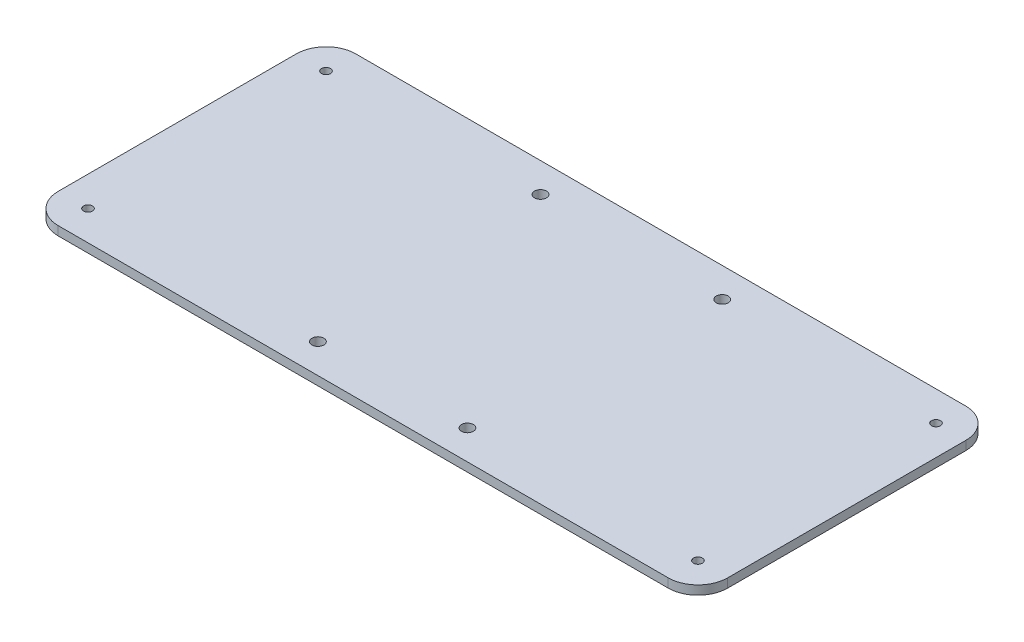
from build123d import *

# Parameters (mm, degrees)
SKETCH1_W           = 225
SKETCH1_H           = 100
SKETCH1_R           = 1.5
SKETCH1_R_2         = 2
BOSS_EXTRUDE1_DEPTH = 3
FILLET1_R           = 10


with BuildPart() as part:
    # Sketch1 → Boss-Extrude1 (new body)
    with BuildSketch(Plane(origin=(0, 0, 0), x_dir=(1, 0, 0), z_dir=(0, 1, 0))):
        Rectangle(SKETCH1_W, SKETCH1_H)
        with Locations((-102.5, 40)):
            Circle(SKETCH1_R, mode=Mode.SUBTRACT)
        with Locations((102.5, 40)):
            Circle(SKETCH1_R, mode=Mode.SUBTRACT)
        with Locations((-102.5, -40)):
            Circle(SKETCH1_R, mode=Mode.SUBTRACT)
        with Locations((102.5, -40)):
            Circle(SKETCH1_R, mode=Mode.SUBTRACT)
        with Locations((-30.535, 40.11)):
            Circle(SKETCH1_R_2, mode=Mode.SUBTRACT)
        with Locations((30.535, 40.11)):
            Circle(SKETCH1_R_2, mode=Mode.SUBTRACT)
        with Locations((25.125, -40.11)):
            Circle(SKETCH1_R_2, mode=Mode.SUBTRACT)
        with Locations((-25.125, -40.11)):
            Circle(SKETCH1_R_2, mode=Mode.SUBTRACT)
    extrude(amount=BOSS_EXTRUDE1_DEPTH)

    # Fillet1
    fillet1_edges = [part.edges().sort_by_distance(p)[0] for p in [
        (112.5, 1.5, 50),
        (-112.5, 1.5, 50),
        (-112.5, 1.5, -50),
        (112.5, 1.5, -50),
    ]]
    fillet(fillet1_edges, radius=FILLET1_R)


solid = part.part
